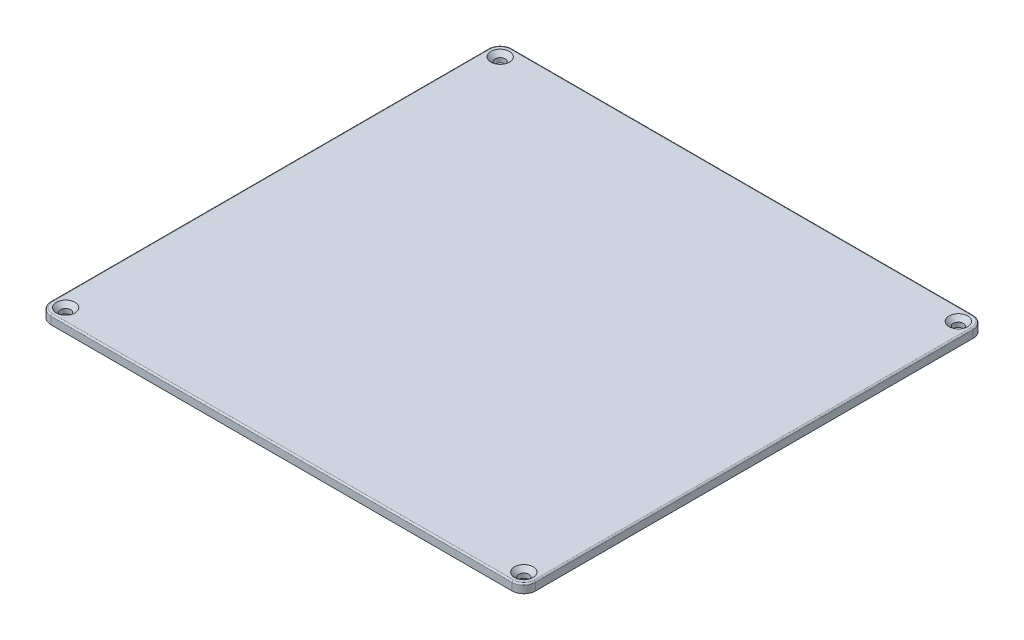
from build123d import *

# Parameters (mm, degrees)
SKETCH1_W                                           = 164
SKETCH1_H                                           = 156
BOSS_EXTRUDE1_DEPTH                                 = 3
BOSS_EXTRUDE2_DEPTH                                 = 3
CUT_EXTRUDE1_DEPTH                                  = 3
FILLET1_R                                           = 4
FILLET2_R                                           = 1
CSK_FOR_M3_COUNTERSUNK_FLAT_HEAD_SCREW1_D           = 3.4
CSK_FOR_M3_COUNTERSUNK_FLAT_HEAD_SCREW1_CSINK_D     = 6.3
CSK_FOR_M3_COUNTERSUNK_FLAT_HEAD_SCREW1_CSINK_ANGLE = 90
FILLET3_R                                           = 0.5


with BuildPart() as part:
    # Sketch1 → Boss-Extrude1 (new body)
    with BuildSketch(Plane(origin=(0, 0, 0), x_dir=(1, 0, 0), z_dir=(0, 1, 0))):
        with Locations((82, 78)):
            Rectangle(SKETCH1_W, SKETCH1_H)
    extrude(amount=BOSS_EXTRUDE1_DEPTH)

    # Sketch2 → Boss-Extrude2 (add)
    with BuildSketch(Plane.XZ):
        with BuildLine():
            Line((10, -3.5), (154, -3.5))
            ThreePointArc((154, -3.5), (155.903805922, -8.096194078), (160.5, -10))
            Line((160.5, -10), (160.5, -146))
            ThreePointArc((160.5, -146), (155.903805922, -147.903805922), (154, -152.5))
            Line((154, -152.5), (10, -152.5))
            ThreePointArc((10, -152.5), (8.096194078, -147.903805922), (3.5, -146))
            Line((3.5, -146), (3.5, -10))
            ThreePointArc((3.5, -10), (8.096194078, -8.096194078), (10, -3.5))
        make_face()
    extrude(amount=BOSS_EXTRUDE2_DEPTH)

    # Sketch4 → Cut-Extrude1 (cut)
    with BuildSketch(Plane.XZ.offset(3)):
        with BuildLine():
            Line((151.486121811, -6.5), (12.513878189, -6.5))
            ThreePointArc((12.513878189, -6.5), (10.217514421, -10.217514421), (6.5, -12.513878189))
            Line((6.5, -12.513878189), (6.5, -143.486121811))
            ThreePointArc((6.5, -143.486121811), (10.217514421, -145.782485579), (12.513878189, -149.5))
            Line((12.513878189, -149.5), (151.486121811, -149.5))
            ThreePointArc((151.486121811, -149.5), (153.782485579, -145.782485579), (157.5, -143.486121811))
            Line((157.5, -143.486121811), (157.5, -12.513878189))
            ThreePointArc((157.5, -12.513878189), (153.782485579, -10.217514421), (151.486121811, -6.5))
        make_face()
    extrude(amount=-CUT_EXTRUDE1_DEPTH, mode=Mode.SUBTRACT)

    # Fillet1
    fillet1_edges = [part.edges().sort_by_distance(p)[0] for p in [
        (0, 1.5, -156),
        (164, 1.5, -156),
        (164, 1.5, 0),
        (0, 1.5, 0),
    ]]
    fillet(fillet1_edges, radius=FILLET1_R)

    # Fillet2
    fillet2_edges = [part.edges().sort_by_distance(p)[0] for p in [
        (160.5, -1.5, -10),
        (154, -1.5, -3.5),
        (10, -1.5, -3.5),
        (3.5, -1.5, -10),
        (3.5, -1.5, -146),
        (10, -1.5, -152.5),
        (154, -1.5, -152.5),
        (160.5, -1.5, -146),
    ]]
    fillet(fillet2_edges, radius=FILLET2_R)

    # CSK for M3 Countersunk Flat Head Screw1 (through all)
    with Locations(Plane(origin=(0, 3, 0), x_dir=(1, 0, 0), z_dir=(0, 1, 0))):
        with Locations((159.5, 4.5), (4.5, 4.5), (4.5, 151.5), (159.5, 151.5)):
            CounterSinkHole(CSK_FOR_M3_COUNTERSUNK_FLAT_HEAD_SCREW1_D / 2, CSK_FOR_M3_COUNTERSUNK_FLAT_HEAD_SCREW1_CSINK_D / 2, counter_sink_angle=CSK_FOR_M3_COUNTERSUNK_FLAT_HEAD_SCREW1_CSINK_ANGLE)

    # Fillet3
    fillet3_edges = [part.edges().sort_by_distance(p)[0] for p in [
        (82, 3, 0),
        (0, 3, -78),
        (164, 3, -78),
        (82, 3, -156),
        (162.828427125, 3, -1.171572875),
        (162.828427125, 3, -154.828427125),
        (1.171572875, 3, -154.828427125),
        (1.171572875, 3, -1.171572875),
    ]]
    fillet(fillet3_edges, radius=FILLET3_R)


solid = part.part
